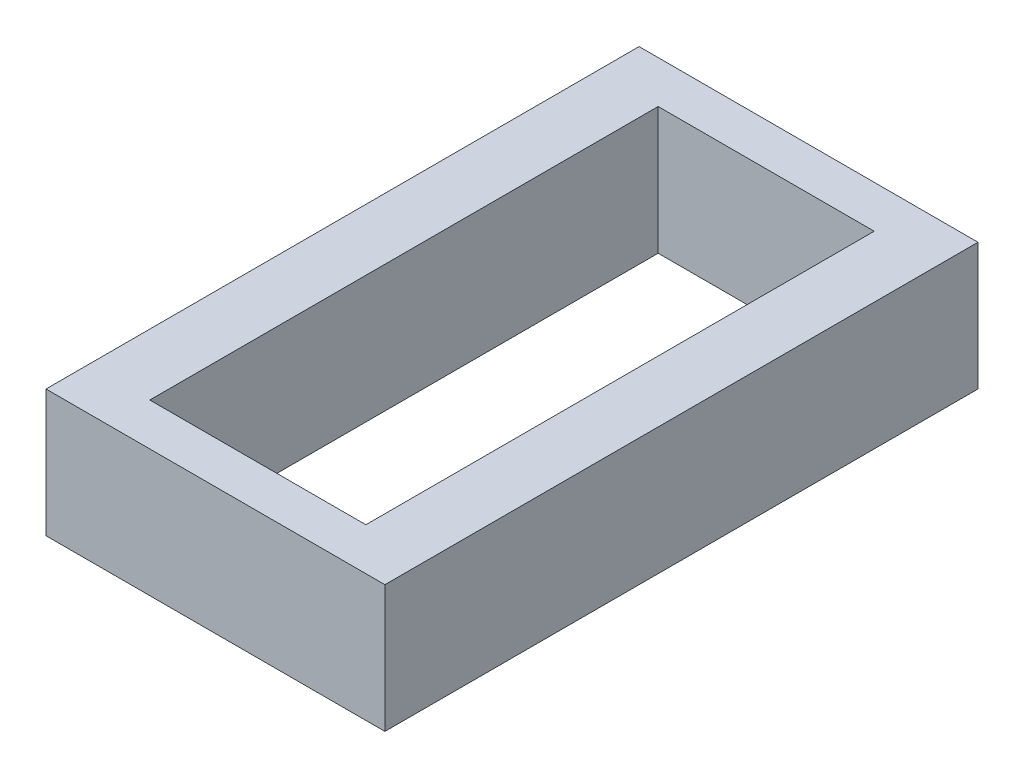
from build123d import *

# Parameters (mm, degrees)
SKETCH1_W           = 8
SKETCH1_H           = 14
SKETCH1_W_2         = 5.1
SKETCH1_H_2         = 12
BOSS_EXTRUDE1_DEPTH = 3


with BuildPart() as part:
    # Sketch1 → Boss-Extrude1 (new body)
    with BuildSketch(Plane(origin=(0, 0, 0), x_dir=(1, 0, 0), z_dir=(0, 1, 0))):
        Rectangle(SKETCH1_W, SKETCH1_H)
        Rectangle(SKETCH1_W_2, SKETCH1_H_2, mode=Mode.SUBTRACT)
    extrude(amount=BOSS_EXTRUDE1_DEPTH)


solid = part.part
